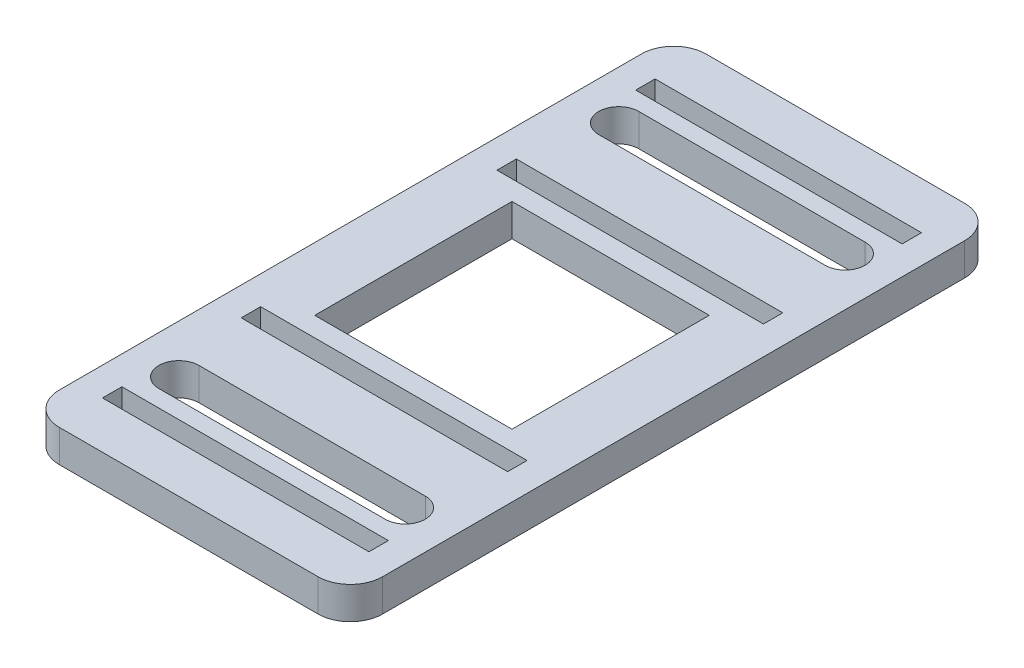
from build123d import *

# Parameters (mm, degrees)
SKETCH1_W           = 50
SKETCH1_H           = 100
BOSS_EXTRUDE1_DEPTH = 5
CUT_EXTRUDE1_START  = -6
CUT_EXTRUDE1_DEPTH  = 7
FILLET1_R           = 5
SKETCH3_W           = 30.5
SKETCH3_H           = 30.5
CUT_EXTRUDE2_DEPTH  = 6
CUT_EXTRUDE3_START  = -6
SKETCH4_W           = 41.2
SKETCH4_H           = 3
CUT_EXTRUDE3_DEPTH  = 7


with BuildPart() as part:
    # Sketch1 → Boss-Extrude1 (new body)
    with BuildSketch(Plane(origin=(0, 0, 0), x_dir=(1, 0, 0), z_dir=(0, 1, 0))):
        Rectangle(SKETCH1_W, SKETCH1_H)
    extrude(amount=BOSS_EXTRUDE1_DEPTH)

    # Sketch2 → Cut-Extrude1 (cut)
    with BuildSketch(Plane(origin=(0, 5, 0), x_dir=(1, 0, 0), z_dir=(0, 1, 0)).offset(CUT_EXTRUDE1_START)):
        with BuildLine():
            Line((-17.5, -30.91), (17.5, -30.91))
            ThreePointArc((17.5, -30.91), (20.6, -34.01), (17.5, -37.11))
            Line((17.5, -37.11), (-17.5, -37.11))
            ThreePointArc((-17.5, -37.11), (-20.6, -34.01), (-17.5, -30.91))
        make_face()
    cut_extrude1 = extrude(amount=CUT_EXTRUDE1_DEPTH, mode=Mode.SUBTRACT)

    # Mirror1: Cut-Extrude1 across plane
    add(cut_extrude1.mirror(Plane.XY), mode=Mode.SUBTRACT)

    # Fillet1
    fillet1_edges = [part.edges().sort_by_distance(p)[0] for p in [
        (25, 2.5, 50),
        (-25, 2.5, 50),
        (-25, 2.5, -50),
        (25, 2.5, -50),
    ]]
    fillet(fillet1_edges, radius=FILLET1_R)

    # Sketch3 → Cut-Extrude2 (cut, through all)
    with BuildSketch(Plane(origin=(0, 5, 0), x_dir=(1, 0, 0), z_dir=(0, 1, 0))):
        Rectangle(SKETCH3_W, SKETCH3_H)
    extrude(amount=-CUT_EXTRUDE2_DEPTH, mode=Mode.SUBTRACT)

    # Sketch4 → Cut-Extrude3 (cut)
    with BuildSketch(Plane(origin=(0, 5, 0), x_dir=(1, 0, 0), z_dir=(0, 1, 0)).offset(CUT_EXTRUDE3_START)):
        with Locations((0, -19.775)):
            Rectangle(SKETCH4_W, SKETCH4_H)
        with Locations((0, -41.225)):
            Rectangle(SKETCH4_W, SKETCH4_H)
    cut_extrude3 = extrude(amount=CUT_EXTRUDE3_DEPTH, mode=Mode.SUBTRACT)

    # Mirror2: Cut-Extrude3 across plane
    add(cut_extrude3.mirror(Plane.XY), mode=Mode.SUBTRACT)


solid = part.part
